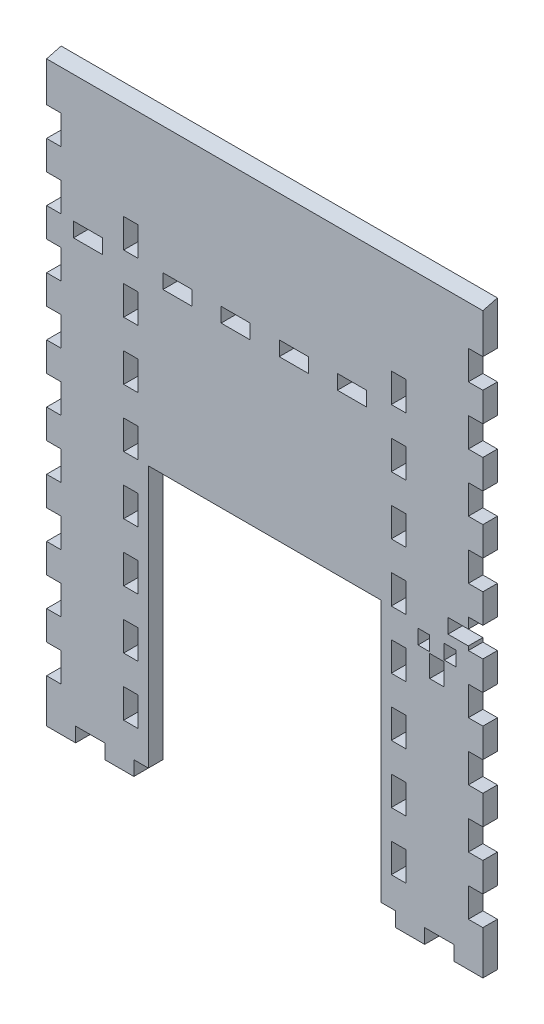
from build123d import *

# Parameters (mm, degrees)
CROQUIS1_W              = 5
CROQUIS1_H              = 10
CROQUIS1_W_2            = 10
CROQUIS1_H_2            = 5
SALIENTE_EXTRUIR1_DEPTH = 5
CORTAR_EXTRUIR7_DEPTH   = 151
CROQUIS8_W              = 4
CROQUIS8_H              = 5
CROQUIS8_W_2            = 5
CROQUIS8_H_2            = 7.5
CROQUIS8_W_3            = 7
CORTAR_EXTRUIR12_DEPTH  = 10


with BuildPart() as part:
    # Croquis1 → Saliente-Extruir1 (new body)
    with BuildSketch(Plane.XY):
        Polygon((0, 0), (10, 0), (10, 5), (20, 5), (20, 0), (30, 0), (30, 5), (35, 5), (35, 95), (115, 95), (115, 5), (117.5, 5), (120, 5), (120, 0), (130, 0), (130, 5), (140, 5), (140, 0), (150, 0), (150, 15), (145, 15), (145, 25), (150, 25), (150, 35), (145, 35), (145, 45), (150, 45), (150, 55), (145, 55), (145, 65), (150, 65), (150, 75), (145, 75), (145, 85), (150, 85), (150, 95), (145, 95), (145, 105), (150, 105), (150, 115), (145, 115), (145, 125), (150, 125), (150, 135), (145, 135), (145, 145), (150, 145), (150, 155), (145, 155), (145, 165), (150, 165), (150, 175), (145, 175), (145, 185), (150, 185), (150, 200), (0, 200), (0, 185), (5, 185), (5, 175), (0, 175), (0, 165), (5, 165), (5, 155), (0, 155), (0, 145), (5, 145), (5, 135), (0, 135), (0, 125), (5, 125), (5, 115), (0, 115), (0, 105), (5, 105), (5, 95), (0, 95), (0, 85), (5, 85), (5, 75), (0, 75), (0, 65), (5, 65), (5, 55), (0, 55), (0, 45), (5, 45), (5, 35), (0, 35), (0, 25), (5, 25), (5, 15), (0, 15), align=None)
        with Locations((28.99995, 20)):
            Rectangle(CROQUIS1_W, CROQUIS1_H, mode=Mode.SUBTRACT)
        with Locations((28.99995, 40)):
            Rectangle(CROQUIS1_W, CROQUIS1_H, mode=Mode.SUBTRACT)
        with Locations((28.99995, 60)):
            Rectangle(CROQUIS1_W, CROQUIS1_H, mode=Mode.SUBTRACT)
        with Locations((28.99995, 80)):
            Rectangle(CROQUIS1_W, CROQUIS1_H, mode=Mode.SUBTRACT)
        with Locations((28.99995, 100)):
            Rectangle(CROQUIS1_W, CROQUIS1_H, mode=Mode.SUBTRACT)
        with Locations((121.00005, 20)):
            Rectangle(CROQUIS1_W, CROQUIS1_H, mode=Mode.SUBTRACT)
        with Locations((121.00005, 40)):
            Rectangle(CROQUIS1_W, CROQUIS1_H, mode=Mode.SUBTRACT)
        with Locations((121.0005, 60)):
            Rectangle(CROQUIS1_W, CROQUIS1_H, mode=Mode.SUBTRACT)
        with Locations((121.00005, 80)):
            Rectangle(CROQUIS1_W, CROQUIS1_H, mode=Mode.SUBTRACT)
        with Locations((121.00005, 100)):
            Rectangle(CROQUIS1_W, CROQUIS1_H, mode=Mode.SUBTRACT)
        with Locations((28.99995, 120)):
            Rectangle(CROQUIS1_W, CROQUIS1_H, mode=Mode.SUBTRACT)
        with Locations((28.99995, 140)):
            Rectangle(CROQUIS1_W, CROQUIS1_H, mode=Mode.SUBTRACT)
        with Locations((14.25, 152.5)):
            Rectangle(CROQUIS1_W_2, CROQUIS1_H_2, mode=Mode.SUBTRACT)
        with Locations((28.99995, 160)):
            Rectangle(CROQUIS1_W, CROQUIS1_H, mode=Mode.SUBTRACT)
        with Locations((45, 152.5)):
            Rectangle(CROQUIS1_W_2, CROQUIS1_H_2, mode=Mode.SUBTRACT)
        with Locations((65, 152.5)):
            Rectangle(CROQUIS1_W_2, CROQUIS1_H_2, mode=Mode.SUBTRACT)
        with Locations((121.00005, 120)):
            Rectangle(CROQUIS1_W, CROQUIS1_H, mode=Mode.SUBTRACT)
        with Locations((121.00005, 140)):
            Rectangle(CROQUIS1_W, CROQUIS1_H, mode=Mode.SUBTRACT)
        with Locations((85, 152.5)):
            Rectangle(CROQUIS1_W_2, CROQUIS1_H_2, mode=Mode.SUBTRACT)
        with Locations((105, 152.5)):
            Rectangle(CROQUIS1_W_2, CROQUIS1_H_2, mode=Mode.SUBTRACT)
        with Locations((121.00005, 160)):
            Rectangle(CROQUIS1_W, CROQUIS1_H, mode=Mode.SUBTRACT)
    extrude(amount=SALIENTE_EXTRUIR1_DEPTH)

    # Croquis7 → Cortar-Extruir7 (cut, through all)
    with BuildSketch(Plane.ZY):
        Polygon((0, 200), (5.317351356, 198.600697011), (5, 200), align=None)
    extrude(amount=-CORTAR_EXTRUIR7_DEPTH, mode=Mode.SUBTRACT)

    # Croquis8 → Cortar-Extruir12 (cut)
    with BuildSketch(Plane.XY.offset(5)):
        with Locations((129.70005, 90.5)):
            Rectangle(CROQUIS8_W, CROQUIS8_H)
        with Locations((134.20005, 83.75)):
            Rectangle(CROQUIS8_W_2, CROQUIS8_H_2)
        with Locations((138.70005, 90.5)):
            Rectangle(CROQUIS8_W, CROQUIS8_H)
        with Locations((141.5, 98.875)):
            Rectangle(CROQUIS8_W_3, CROQUIS8_H)
    extrude(amount=-CORTAR_EXTRUIR12_DEPTH, mode=Mode.SUBTRACT)


solid = part.part
